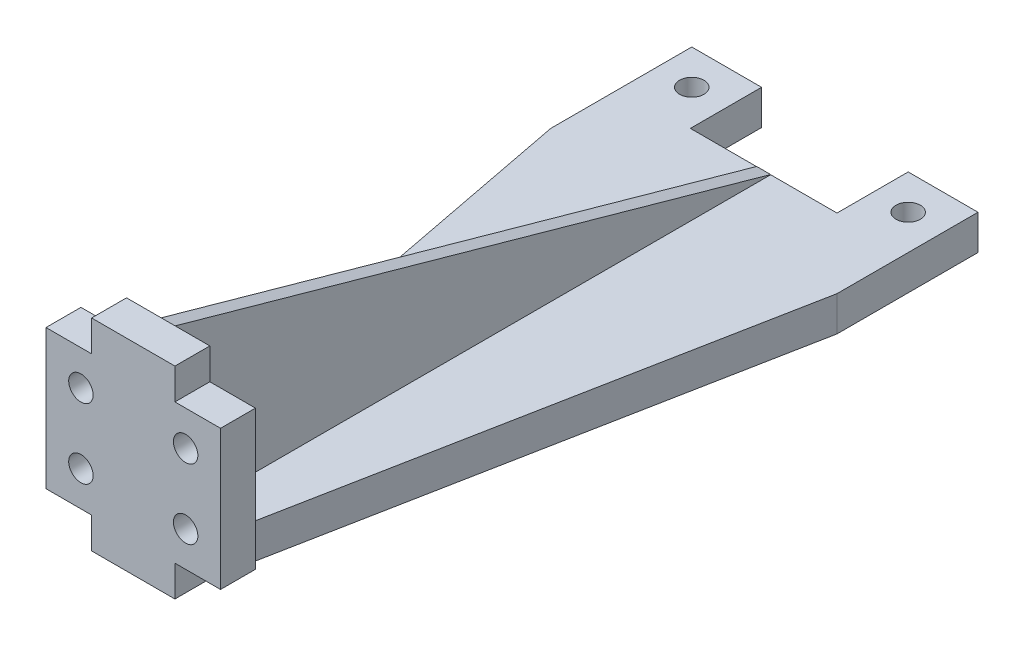
from build123d import *

# Parameters (mm, degrees)
SKETCH1_W           = 41
SKETCH1_H           = 100.5
BOSS_EXTRUDE1_DEPTH = 5
SKETCH2_W           = 21
SKETCH2_H           = 10.2
CUT_EXTRUDE1_DEPTH  = 6
SKETCH9_R           = 1.75
CUT_EXTRUDE4_DEPTH  = 6
CUT_EXTRUDE5_DEPTH  = 6
BOSS_EXTRUDE4_DEPTH = 23.9
SKETCH16_W          = 2
SKETCH16_H          = 85.3
BOSS_EXTRUDE5_DEPTH = 23.9
CUT_EXTRUDE8_DEPTH  = 22.5
BOSS_EXTRUDE6_DEPTH = 28.9
SKETCH25_W          = 6.53486924
SKETCH25_H          = 4.45
CUT_EXTRUDE9_DEPTH  = 6
SKETCH26_R          = 1.75
CUT_EXTRUDE10_DEPTH = 101.5


with BuildPart() as part:
    # Sketch1 → Boss-Extrude1 (new body)
    with BuildSketch(Plane(origin=(0, 0, 0), x_dir=(1, 0, 0), z_dir=(0, 1, 0))):
        with Locations((20.5, 50.25)):
            Rectangle(SKETCH1_W, SKETCH1_H)
    extrude(amount=BOSS_EXTRUDE1_DEPTH)

    # Sketch2 → Cut-Extrude1 (cut, through all)
    with BuildSketch(Plane(origin=(0, 5, 0), x_dir=(1, 0, 0), z_dir=(0, 1, 0))):
        with Locations((20.5, 95.4)):
            Rectangle(SKETCH2_W, SKETCH2_H)
    extrude(amount=-CUT_EXTRUDE1_DEPTH, mode=Mode.SUBTRACT)

    # Sketch9 → Cut-Extrude4 (cut, through all)
    with BuildSketch(Plane(origin=(0, 5, 0), x_dir=(1, 0, 0), z_dir=(0, 1, 0))):
        with Locations((5, 95.5)):
            Circle(SKETCH9_R)
        with Locations((36, 95.5)):
            Circle(SKETCH9_R)
    extrude(amount=-CUT_EXTRUDE4_DEPTH, mode=Mode.SUBTRACT)

    # Sketch11 → Cut-Extrude5 (cut, through all)
    with BuildSketch(Plane(origin=(0, 5, 0), x_dir=(1, 0, 0), z_dir=(0, 1, 0))):
        Polygon((15.5, 0), (0, 80.3), (0, 0), align=None)
        Polygon((25.5, 0), (41, 80.3), (41, 0), align=None)
    extrude(amount=-CUT_EXTRUDE5_DEPTH, mode=Mode.SUBTRACT)

    # Sketch12 → Boss-Extrude4 (add)
    with BuildSketch(Plane(origin=(0, 5, 0), x_dir=(1, 0, 0), z_dir=(0, 1, 0))):
        Polygon((25.5, 0), (15.5, 0), (14.53486924, 5), (26.46513076, 5), align=None)
    extrude(amount=BOSS_EXTRUDE4_DEPTH)

    # Sketch16 → Boss-Extrude5 (add)
    with BuildSketch(Plane(origin=(0, 5, 0), x_dir=(1, 0, 0), z_dir=(0, 1, 0))):
        with Locations((20.5, 47.65)):
            Rectangle(SKETCH16_W, SKETCH16_H)
    extrude(amount=BOSS_EXTRUDE5_DEPTH)

    # Sketch17 → Cut-Extrude8 (cut, through all)
    with BuildSketch(Plane.ZY.offset(-19.5)):
        Polygon((-90.4, 5), (-5, 28.9), (-90.3, 28.9), align=None)
    extrude(amount=-CUT_EXTRUDE8_DEPTH, mode=Mode.SUBTRACT)

    # Sketch23 → Boss-Extrude6 (add)
    with BuildSketch(Plane(origin=(0, 28.9, 0), x_dir=(1, 0, 0), z_dir=(0, 1, 0))):
        Polygon((26.46513076, 5), (33, 5), (33, 0), (25.5, 0), align=None)
        Polygon((14.53486924, 5), (8, 5), (8, 0), (15.5, 0), align=None)
    extrude(amount=-BOSS_EXTRUDE6_DEPTH)

    # Sketch25 → Cut-Extrude9 (cut, through all)
    with BuildSketch(Plane(origin=(0, 0, -5), x_dir=(-1, 0, 0), z_dir=(0, 0, -1))):
        with Locations((-11.26743462, 2.225)):
            Rectangle(SKETCH25_W, SKETCH25_H)
        with Locations((-29.73256538, 2.225)):
            Rectangle(SKETCH25_W, SKETCH25_H)
        with Locations((-11.26743462, 26.675)):
            Rectangle(SKETCH25_W, SKETCH25_H)
        with Locations((-29.73256538, 26.675)):
            Rectangle(SKETCH25_W, SKETCH25_H)
    extrude(amount=-CUT_EXTRUDE9_DEPTH, mode=Mode.SUBTRACT)

    # Sketch26 → Cut-Extrude10 (cut, through all)
    with BuildSketch(Plane.XY):
        with Locations((13, 19.45)):
            Circle(SKETCH26_R)
        with Locations((28, 19.45)):
            Circle(SKETCH26_R)
        with Locations((13, 9.45)):
            Circle(SKETCH26_R)
        with Locations((28, 9.45)):
            Circle(SKETCH26_R)
    extrude(amount=-CUT_EXTRUDE10_DEPTH, mode=Mode.SUBTRACT)


solid = part.part
